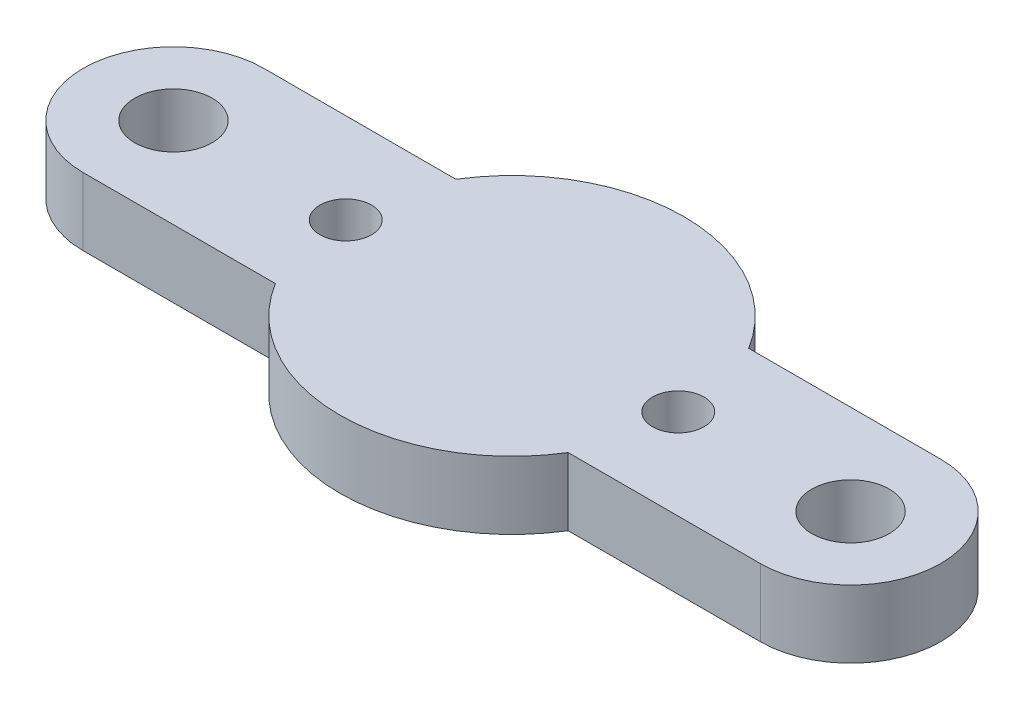
from build123d import *

# Parameters (mm, degrees)
SKETCH1_R           = 1.143
SKETCH1_R_2         = 1.7145
BOSS_EXTRUDE1_DEPTH = 3


with BuildPart() as part:
    # Sketch1 → Boss-Extrude1 (new body)
    with BuildSketch(Plane(origin=(0, 0, 0), x_dir=(1, 0, 0), z_dir=(0, 1, 0))):
        with BuildLine():
            Line((-15, 4), (-6.485707363, 4))
            ThreePointArc((-6.485707363, 4), (0, 7.62), (6.485707363, 4))
            Line((6.485707363, 4), (15, 4))
            ThreePointArc((15, 4), (19, 0), (15, -4))
            Line((15, -4), (6.485707363, -4))
            ThreePointArc((6.485707363, -4), (0, -7.62), (-6.485707363, -4))
            Line((-6.485707363, -4), (-15, -4))
            ThreePointArc((-15, -4), (-19, 0), (-15, 4))
        make_face()
        with Locations((-7.366, 0)):
            Circle(SKETCH1_R, mode=Mode.SUBTRACT)
        with Locations((7.366, 0)):
            Circle(SKETCH1_R, mode=Mode.SUBTRACT)
        with Locations((-15, 0)):
            Circle(SKETCH1_R_2, mode=Mode.SUBTRACT)
        with Locations((15, 0)):
            Circle(SKETCH1_R_2, mode=Mode.SUBTRACT)
    extrude(amount=BOSS_EXTRUDE1_DEPTH)


solid = part.part
